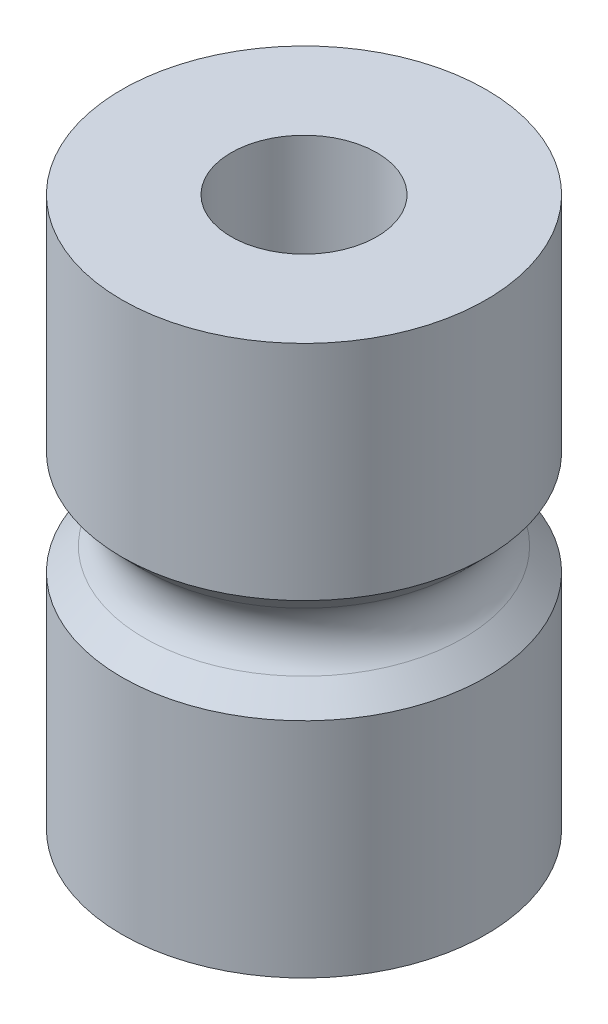
from build123d import *

# Parameters (mm, degrees)
FILLET1_R = 2.54


with BuildPart() as part:
    # Sketch2 → Revolve1 (revolve)
    with BuildSketch(Plane.XY):
        Polygon((4.445, 0), (11.1125, 0), (11.1125, 13.589), (7.9375, 16.764), (11.1125, 19.939), (11.1125, 33.528), (4.445, 33.528), align=None)
    revolve(axis=Axis((0, 0, 0), (0, 1, 0)))

    # Fillet1
    fillet1_edges = [part.edges().sort_by_distance(p)[0] for p in [
        (-7.9375, 16.764, 0),
    ]]
    fillet(fillet1_edges, radius=FILLET1_R)


solid = part.part
